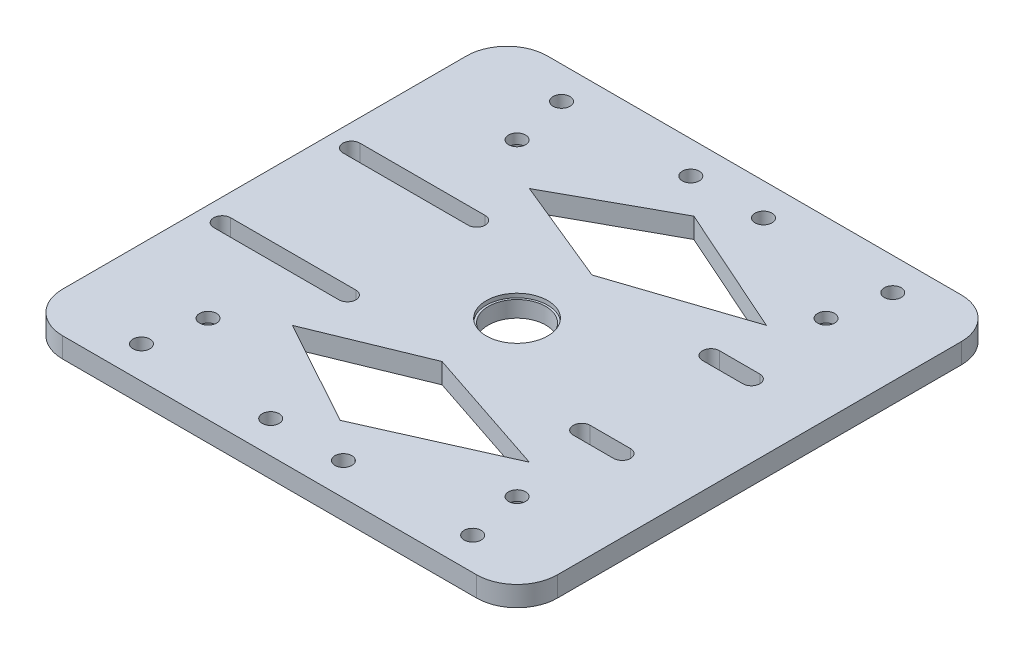
from build123d import *

# Parameters (mm, degrees)
SKETCH2_R               = 2.1
SKETCH2_R_2             = 7.1
BOSS_EXTRUDE1_DEPTH     = 5
SKETCH3_R               = 7.6
CUT_EXTRUDE1_DEPTH      = 1
SKETCH4_R               = 2.1
CUT_EXTRUDE2_DEPTH      = 6
SKETCH5_R               = 4
CUT_EXTRUDE3_DEPTH      = 2.5
CUT_EXTRUDE4_DEPTH      = 6
CUT_EXTRUDE5_DEPTH      = 6
CUT_EXTRUDE6_DEPTH      = 1
CUT_EXTRUDE6_DEPTH_BACK = 6


with BuildPart() as part:
    # Sketch2 → Boss-Extrude1 (new body)
    with BuildSketch(Plane(origin=(0, 0, 0), x_dir=(1, 0, 0), z_dir=(0, 1, 0))):
        with BuildLine():
            Line((50, 60), (-52.5, 60))
            ThreePointArc((-52.5, 60), (-59.571067812, 57.071067812), (-62.5, 50))
            Line((-62.5, 50), (-62.5, -50))
            ThreePointArc((-62.5, -50), (-59.571067812, -57.071067812), (-52.5, -60))
            Line((-52.5, -60), (50, -60))
            ThreePointArc((50, -60), (57.071067812, -57.071067812), (60, -50))
            Line((60, -50), (60, 50))
            ThreePointArc((60, 50), (57.071067812, 57.071067812), (50, 60))
        make_face()
        with Locations((-38.25, -38.25)):
            Circle(SKETCH2_R, mode=Mode.SUBTRACT)
        with Locations((38.25, -38.25)):
            Circle(SKETCH2_R, mode=Mode.SUBTRACT)
        with Locations((-38.25, 38.25)):
            Circle(SKETCH2_R, mode=Mode.SUBTRACT)
        Circle(SKETCH2_R_2, mode=Mode.SUBTRACT)
        with Locations((38.25, 38.25)):
            Circle(SKETCH2_R, mode=Mode.SUBTRACT)
    extrude(amount=BOSS_EXTRUDE1_DEPTH)

    # Sketch3 → Cut-Extrude1 (cut)
    with BuildSketch(Plane(origin=(0, 5, 0), x_dir=(1, 0, 0), z_dir=(0, 1, 0))):
        Circle(SKETCH3_R)
    extrude(amount=-CUT_EXTRUDE1_DEPTH, mode=Mode.SUBTRACT)

    # Sketch4 → Cut-Extrude2 (cut, through all)
    with BuildSketch(Plane.XZ):
        with Locations((-40.988809693, -52)):
            Circle(SKETCH4_R)
        with Locations((-8.988809693, -52)):
            Circle(SKETCH4_R)
        with Locations((9.011190307, -52)):
            Circle(SKETCH4_R)
        with Locations((41.011190307, -52)):
            Circle(SKETCH4_R)
        with BuildLine():
            ThreePointArc((-43.088809693, 52), (-40.988809693, 49.9), (-38.888809693, 52))
            Line((-38.888809693, 52), (-43.088809693, 52))
        make_face()
        with BuildLine():
            Line((-43.088809693, 52), (-38.888809693, 52))
            ThreePointArc((-38.888809693, 52), (-40.988809693, 54.1), (-43.088809693, 52))
        make_face()
        with BuildLine():
            ThreePointArc((-6.888809693, 52), (-8.988809693, 54.1), (-11.088809693, 52))
            Line((-11.088809693, 52), (-6.888809693, 52))
        make_face()
        with BuildLine():
            Line((-6.888809693, 52), (-11.088809693, 52))
            ThreePointArc((-11.088809693, 52), (-8.988809693, 49.9), (-6.888809693, 52))
        make_face()
        with Locations((9.011190307, 52)):
            Circle(SKETCH4_R)
        with Locations((41.011190307, 52)):
            Circle(SKETCH4_R)
    extrude(amount=-CUT_EXTRUDE2_DEPTH, mode=Mode.SUBTRACT)

    # Sketch5 → Cut-Extrude3 (cut)
    with BuildSketch(Plane.XZ):
        with Locations((-38.25, 38.25)):
            Circle(SKETCH5_R)
        with Locations((38.25, 38.25)):
            Circle(SKETCH5_R)
        with Locations((38.25, -38.25)):
            Circle(SKETCH5_R)
        with Locations((-38.25, -38.25)):
            Circle(SKETCH5_R)
    extrude(amount=-CUT_EXTRUDE3_DEPTH, mode=Mode.SUBTRACT)

    # Sketch7 → Cut-Extrude4 (cut, through all)
    with BuildSketch(Plane.XZ):
        with BuildLine():
            Line((32, 18.1), (42, 18.1))
            ThreePointArc((42, 18.1), (44.1, 16), (42, 13.9))
            Line((42, 13.9), (32, 13.9))
            ThreePointArc((32, 13.9), (29.9, 16), (32, 18.1))
        make_face()
        with BuildLine():
            Line((32, -13.9), (42, -13.9))
            ThreePointArc((42, -13.9), (44.1, -16), (42, -18.1))
            Line((42, -18.1), (32, -18.1))
            ThreePointArc((32, -18.1), (29.9, -16), (32, -13.9))
        make_face()
    extrude(amount=-CUT_EXTRUDE4_DEPTH, mode=Mode.SUBTRACT)

    # Sketch8 → Cut-Extrude5 (cut, through all)
    with BuildSketch(Plane.XZ):
        with BuildLine():
            Line((-57, 18.1), (-26, 18.1))
            ThreePointArc((-26, 18.1), (-23.9, 16), (-26, 13.9))
            Line((-26, 13.9), (-57, 13.9))
            ThreePointArc((-57, 13.9), (-59.1, 16), (-57, 18.1))
        make_face()
        with BuildLine():
            Line((-57, -13.9), (-26, -13.9))
            ThreePointArc((-26, -13.9), (-23.9, -16), (-26, -18.1))
            Line((-26, -18.1), (-57, -18.1))
            ThreePointArc((-57, -18.1), (-59.1, -16), (-57, -13.9))
        make_face()
    extrude(amount=-CUT_EXTRUDE5_DEPTH, mode=Mode.SUBTRACT)

    # Sketch9 → Cut-Extrude6 (cut, two sides)
    with BuildSketch(Plane(origin=(0, 5, 0), x_dir=(1, 0, 0), z_dir=(0, 1, 0))) as cut_extrude6_sk:
        Polygon((0, -18.55416869), (-26.293557739, -29.33935049), (0, -43.78052612), (32.385143241, -29.33935049), align=None)
        Polygon((0, 43.78052612), (32.385143241, 29.33935049), (0, 18.55416869), (-26.293557739, 29.33935049), align=None)
    extrude(amount=CUT_EXTRUDE6_DEPTH, mode=Mode.SUBTRACT)
    extrude(cut_extrude6_sk.sketch, amount=-CUT_EXTRUDE6_DEPTH_BACK, mode=Mode.SUBTRACT)


solid = part.part
